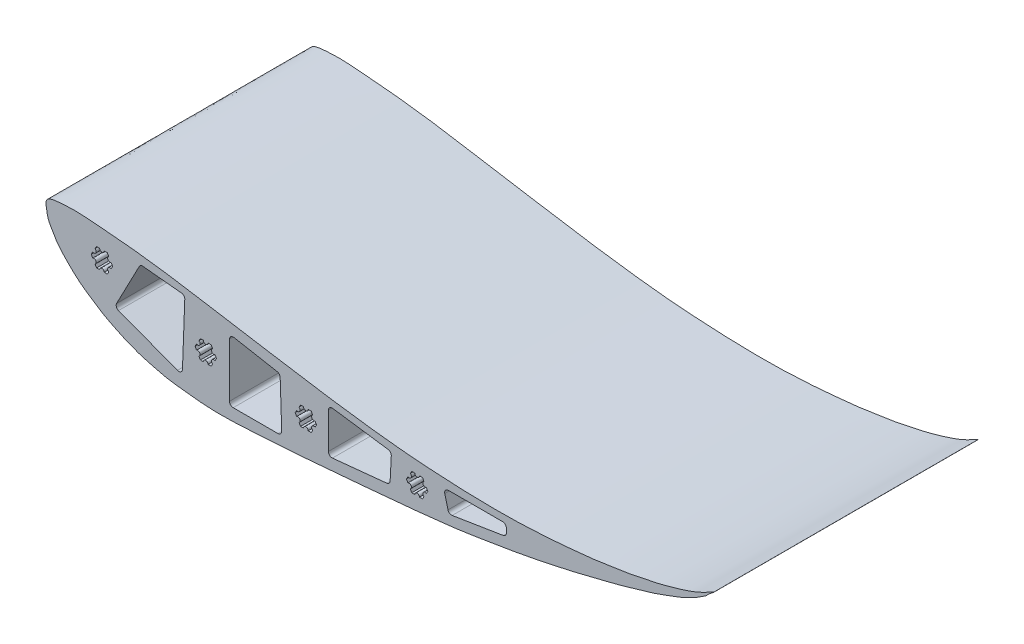
from build123d import *

# Parameters (mm, degrees)
BOSS_EXTRUDE1_DEPTH = 180.975
CUT_EXTRUDE3_DEPTH  = 381


with BuildPart() as part:
    # Sketch1 → Boss-Extrude1 (new body)
    with BuildSketch(Plane.XY):
        with BuildLine():
            add(Edge.make_bspline(
                [(-16.622525288, 91.56967272), (-16.794942994, 92.772317911), (-17.515788121, 97.582670832), (-2.852582554, 99.497127174), (9.154054709, 99.213304724), (23.433217875, 97.797752429), (34.6859051, 97.019819773), (46.592767258, 95.707761604), (58.472171701, 94.254609297), (72.666253463, 92.219697635), (88.15460255, 89.685431784), (109.15740223, 86.162485471), (130.076144789, 82.711728928), (150.055716296, 79.576696099), (168.256858053, 76.617688262), (186.559493812, 73.857794613), (206.695059336, 71.20791695), (225.195546149, 69.114961125), (244.068606399, 67.656695297), (262.594452449, 66.476567979), (282.222526995, 65.926744761), (300.99609332, 65.813021246), (318.737894065, 66.539084176), (334.742865336, 67.61277327), (348.252438633, 69.009944705), (359.067906447, 70.049570339), (367.896874578, 71.420704301), (377.007425502, 72.883057797), (386.227823421, 74.138373924), (395.367743176, 76.385575861), (403.564697097, 77.907582397), (410.735250399, 79.953005658), (417.114285798, 81.687412008), (422.732680223, 83.591992804), (427.164087313, 85.094079009), (431.171696898, 86.937153076), (434.607250511, 88.392786361), (443.123217376, 93.275688905), (437.255094337, 89.117703468), (435.279778464, 86.561175616), (431.573501891, 84.704524529), (428.464842726, 82.201032813), (424.134266462, 80.398696308), (419.425258521, 77.797857577), (414.105440345, 75.713007702), (408.77839072, 73.798734141), (403.684867312, 72.029145889), (396.961540144, 69.466067962), (387.343622202, 67.136732033), (376.830663922, 63.608926675), (365.24798357, 60.901656463), (354.754672426, 58.255886458), (344.650791699, 55.720154361), (336.670341174, 53.941801639), (329.235250959, 52.381752299), (321.327868225, 50.676833739), (310.892392252, 48.725728026), (298.426712372, 46.308387166), (284.136528131, 44.189578856), (268.909448728, 41.574011521), (251.075314715, 39.596728872), (229.386892765, 37.203012777), (203.753382466, 34.933554815), (177.46976253, 32.720447696), (150.443659112, 30.344574846), (123.02307167, 28.688327838), (101.004781565, 27.555963663), (84.804305156, 28.931500406), (75.72348416, 30.010523718), (67.270753352, 30.977463397), (60.250592801, 32.582425676), (53.932519662, 34.232006507), (47.114759922, 36.133551764), (41.43120503, 38.368275103), (36.428795002, 40.445297648), (32.069577899, 42.402430324), (27.662403595, 44.667790264), (23.104788958, 46.965799851), (18.73168781, 49.734821084), (12.723675127, 53.669846892), (5.809434759, 58.404883079), (-1.037305312, 65.077409289), (-6.513200759, 70.614178991), (-10.540658158, 76.008047875), (-12.880350205, 80.406543609), (-15.167480815, 84.128221175), (-16.123087236, 87.961419413), (-16.453570873, 90.391184614), (-16.622525288, 91.56967272)],
                knots=[0, 0, 0, 0, 0.003644297, 0.013581344, 0.034074787, 0.047557163, 0.057150579, 0.06958931, 0.084962672, 0.094623108, 0.114452008, 0.134073068, 0.161263036, 0.180794832, 0.197357561, 0.218965716, 0.238711125, 0.26090768, 0.277214827, 0.297940316, 0.318988728, 0.338651177, 0.356673355, 0.374539934, 0.388835783, 0.399172974, 0.408530924, 0.416784345, 0.428053881, 0.437617365, 0.446213781, 0.454125754, 0.460928052, 0.466918155, 0.472615005, 0.475771621, 0.480179638, 0.487250343, 0.490988881, 0.49507496, 0.498775568, 0.503369536, 0.507624299, 0.513322415, 0.520215853, 0.525455504, 0.531043662, 0.537088919, 0.5479516, 0.561953721, 0.571760074, 0.585151118, 0.595822817, 0.604354359, 0.61073386, 0.619595652, 0.629664863, 0.643953388, 0.659323518, 0.674864947, 0.692287919, 0.715453133, 0.743149301, 0.772805526, 0.797998576, 0.828023399, 0.858832685, 0.866768477, 0.87886578, 0.88746214, 0.893357873, 0.901377327, 0.907903322, 0.915486693, 0.920464298, 0.924856032, 0.930432876, 0.935970498, 0.940815755, 0.946613865, 0.958462559, 0.966932993, 0.97647901, 0.982815006, 0.98789669, 0.992067686, 0.996428904, 1, 1, 1, 1], degree=3))
        make_face()
    extrude(amount=BOSS_EXTRUDE1_DEPTH)

    # Sketch4 → Cut-Extrude3 (cut)
    with BuildSketch(Plane.XY.offset(180.975)):
        with BuildLine():
            Line((88.931300118, 66.243537573), (91.009974327, 66.243537573))
            ThreePointArc((91.009974327, 66.243537573), (92.597474327, 64.656037573), (94.184974327, 66.243537573))
            Line((94.184974327, 66.243537573), (96.263648536, 66.243537573))
            Line((96.263648536, 66.243537573), (97.302985641, 64.443352902))
            ThreePointArc((97.302985641, 64.443352902), (96.721920503, 62.274787243), (98.890486301, 61.693722626))
            Line((98.890486301, 61.693722626), (99.929823515, 59.893537766))
            Line((99.929823515, 59.893537766), (98.89048641, 58.093353094))
            ThreePointArc((98.89048641, 58.093353094), (96.721921082, 57.512287766), (97.30298641, 55.343722437))
            Line((97.30298641, 55.343722437), (96.263649306, 53.543537766))
            Line((96.263649306, 53.543537766), (94.184975096, 53.543537766))
            ThreePointArc((94.184975096, 53.543537766), (92.597475, 55.131037573), (91.009975096, 53.543537573))
            Line((91.009975096, 53.543537573), (88.931300887, 53.543537573))
            Line((88.931300887, 53.543537573), (87.891963673, 55.343722182))
            ThreePointArc((87.891963673, 55.343722182), (88.47302887, 57.512287545), (86.304463507, 58.093352743))
            Line((86.304463507, 58.093352743), (85.265126293, 59.893537351))
            Line((85.265126293, 59.893537351), (86.304463288, 61.693722086))
            ThreePointArc((86.304463288, 61.693722086), (88.473028582, 62.274787545), (87.891963122, 64.443352839))
            Line((87.891963122, 64.443352839), (88.931300118, 66.243537573))
        make_face()
        with BuildLine():
            Line((17.811300118, 85.293537573), (19.889974327, 85.293537573))
            ThreePointArc((19.889974327, 85.293537573), (21.477474327, 83.706037573), (23.064974327, 85.293537573))
            Line((23.064974327, 85.293537573), (25.143648536, 85.293537573))
            Line((25.143648536, 85.293537573), (26.182985641, 83.493352902))
            ThreePointArc((26.182985641, 83.493352902), (25.601920503, 81.324787243), (27.770486301, 80.743722626))
            Line((27.770486301, 80.743722626), (28.809823515, 78.943537766))
            Line((28.809823515, 78.943537766), (27.77048641, 77.143353094))
            ThreePointArc((27.77048641, 77.143353094), (25.601921082, 76.562287766), (26.18298641, 74.393722437))
            Line((26.18298641, 74.393722437), (25.143649306, 72.593537766))
            Line((25.143649306, 72.593537766), (23.064975096, 72.593537766))
            ThreePointArc((23.064975096, 72.593537766), (21.477475, 74.181037573), (19.889975096, 72.593537573))
            Line((19.889975096, 72.593537573), (17.811300887, 72.593537573))
            Line((17.811300887, 72.593537573), (16.771963673, 74.393722182))
            ThreePointArc((16.771963673, 74.393722182), (17.35302887, 76.562287545), (15.184463507, 77.143352743))
            Line((15.184463507, 77.143352743), (14.145126293, 78.943537351))
            Line((14.145126293, 78.943537351), (15.184463288, 80.743722086))
            ThreePointArc((15.184463288, 80.743722086), (17.353028582, 81.324787545), (16.771963122, 83.493352839))
            Line((16.771963122, 83.493352839), (17.811300118, 85.293537573))
        make_face()
        with BuildLine():
            Line((233.711300118, 59.893537573), (235.789974327, 59.893537573))
            ThreePointArc((235.789974327, 59.893537573), (237.377474327, 58.306037573), (238.964974327, 59.893537573))
            Line((238.964974327, 59.893537573), (241.043648536, 59.893537573))
            Line((241.043648536, 59.893537573), (242.082985641, 58.093352902))
            ThreePointArc((242.082985641, 58.093352902), (241.501920503, 55.924787243), (243.670486301, 55.343722626))
            Line((243.670486301, 55.343722626), (244.709823515, 53.543537766))
            Line((244.709823515, 53.543537766), (243.67048641, 51.743353094))
            ThreePointArc((243.67048641, 51.743353094), (241.501921082, 51.162287766), (242.08298641, 48.993722437))
            Line((242.08298641, 48.993722437), (241.043649306, 47.193537766))
            Line((241.043649306, 47.193537766), (238.964975096, 47.193537766))
            ThreePointArc((238.964975096, 47.193537766), (237.377475, 48.781037573), (235.789975096, 47.193537573))
            Line((235.789975096, 47.193537573), (233.711300887, 47.193537573))
            Line((233.711300887, 47.193537573), (232.671963673, 48.993722182))
            ThreePointArc((232.671963673, 48.993722182), (233.25302887, 51.162287545), (231.084463507, 51.743352743))
            Line((231.084463507, 51.743352743), (230.045126293, 53.543537351))
            Line((230.045126293, 53.543537351), (231.084463288, 55.343722086))
            ThreePointArc((231.084463288, 55.343722086), (233.253028582, 55.924787545), (232.671963122, 58.093352839))
            Line((232.671963122, 58.093352839), (233.711300118, 59.893537573))
        make_face()
        with BuildLine():
            Line((157.511300118, 61.163537573), (159.589974327, 61.163537573))
            ThreePointArc((159.589974327, 61.163537573), (161.177474327, 59.576037573), (162.764974327, 61.163537573))
            Line((162.764974327, 61.163537573), (164.843648536, 61.163537573))
            Line((164.843648536, 61.163537573), (165.882985641, 59.363352902))
            ThreePointArc((165.882985641, 59.363352902), (165.301920503, 57.194787243), (167.470486301, 56.613722626))
            Line((167.470486301, 56.613722626), (168.509823515, 54.813537766))
            Line((168.509823515, 54.813537766), (167.47048641, 53.013353094))
            ThreePointArc((167.47048641, 53.013353094), (165.301921082, 52.432287766), (165.88298641, 50.263722437))
            Line((165.88298641, 50.263722437), (164.843649306, 48.463537766))
            Line((164.843649306, 48.463537766), (162.764975096, 48.463537766))
            ThreePointArc((162.764975096, 48.463537766), (161.177475, 50.051037573), (159.589975096, 48.463537573))
            Line((159.589975096, 48.463537573), (157.511300887, 48.463537573))
            Line((157.511300887, 48.463537573), (156.471963673, 50.263722182))
            ThreePointArc((156.471963673, 50.263722182), (157.05302887, 52.432287545), (154.884463507, 53.013352743))
            Line((154.884463507, 53.013352743), (153.845126293, 54.813537351))
            Line((153.845126293, 54.813537351), (154.884463288, 56.613722086))
            ThreePointArc((154.884463288, 56.613722086), (157.053028582, 57.194787545), (156.471963122, 59.363352839))
            Line((156.471963122, 59.363352839), (157.511300118, 61.163537573))
        make_face()
        with BuildLine():
            Line((31.501207482, 58.37669779), (47.032113751, 88.081016492))
            ThreePointArc((47.032113751, 88.081016492), (48.076445172, 89.139261035), (49.534182489, 89.431684603))
            Line((49.534182489, 89.431684603), (75.93058222, 86.808602351))
            ThreePointArc((75.93058222, 86.808602351), (77.593752589, 85.950453195), (78.217633108, 84.185990458))
            Line((78.217633108, 84.185990458), (76.631821885, 41.843273018))
            ThreePointArc((76.631821885, 41.843273018), (75.497981954, 39.821894696), (73.194863199, 39.56265096))
            Line((73.194863199, 39.56265096), (32.853368422, 54.824131949))
            ThreePointArc((32.853368422, 54.824131949), (31.378241648, 56.296285615), (31.501207482, 58.37669779))
        make_face()
        with BuildLine():
            Line((111.858309541, 78.393902518), (141.485442222, 72.962296795))
            ThreePointArc((141.485442222, 72.962296795), (142.950940478, 72.12274223), (143.565962065, 70.549756072))
            Line((143.565962065, 70.549756072), (144.628770085, 39.112135773))
            ThreePointArc((144.628770085, 39.112135773), (143.916361615, 37.260866924), (142.090220332, 36.486315313))
            Line((142.090220332, 36.486315313), (111.400279631, 36.486315313))
            ThreePointArc((111.400279631, 36.486315313), (109.604228407, 37.230264089), (108.860279631, 39.026315313))
            Line((108.860279631, 39.026315313), (108.860279631, 75.895541334))
            ThreePointArc((108.860279631, 75.895541334), (109.774210132, 77.846822448), (111.858309541, 78.393902518))
        make_face()
        with BuildLine():
            Line((179.473393864, 70.165192722), (217.50482476, 64.769576264))
            ThreePointArc((217.50482476, 64.769576264), (219.108331349, 63.86995645), (219.68467301, 62.123995546))
            Line((219.68467301, 62.123995546), (218.890378913, 46.71578744))
            ThreePointArc((218.890378913, 46.71578744), (218.192789678, 45.094545708), (216.607247121, 44.319232678))
            Line((216.607247121, 44.319232678), (179.370110323, 40.58420072))
            ThreePointArc((179.370110323, 40.58420072), (177.412540188, 41.227973149), (176.576610312, 43.111519011))
            Line((176.576610312, 43.111519011), (176.576610312, 67.650375533))
            ThreePointArc((176.576610312, 67.650375533), (177.451472213, 69.568425352), (179.473393864, 70.165192722))
        make_face()
        with BuildLine():
            Line((258.751236774, 61.163537573), (296.003687002, 61.163537573))
            ThreePointArc((296.003687002, 61.163537573), (297.799738226, 60.419588797), (298.543687002, 58.623537573))
            Line((298.543687002, 58.623537573), (298.543687002, 55.707363059))
            ThreePointArc((298.543687002, 55.707363059), (297.937199117, 54.060204626), (296.407363457, 53.199645906))
            Line((296.407363457, 53.199645906), (261.377375447, 47.560739881))
            ThreePointArc((261.377375447, 47.560739881), (259.584877656, 47.941775277), (258.515299797, 49.429807368))
            Line((258.515299797, 49.429807368), (256.292837579, 57.984887907))
            ThreePointArc((256.292837579, 57.984887907), (256.742036666, 60.177472876), (258.751236774, 61.163537573))
        make_face()
    extrude(amount=-CUT_EXTRUDE3_DEPTH, mode=Mode.SUBTRACT)


solid = part.part
